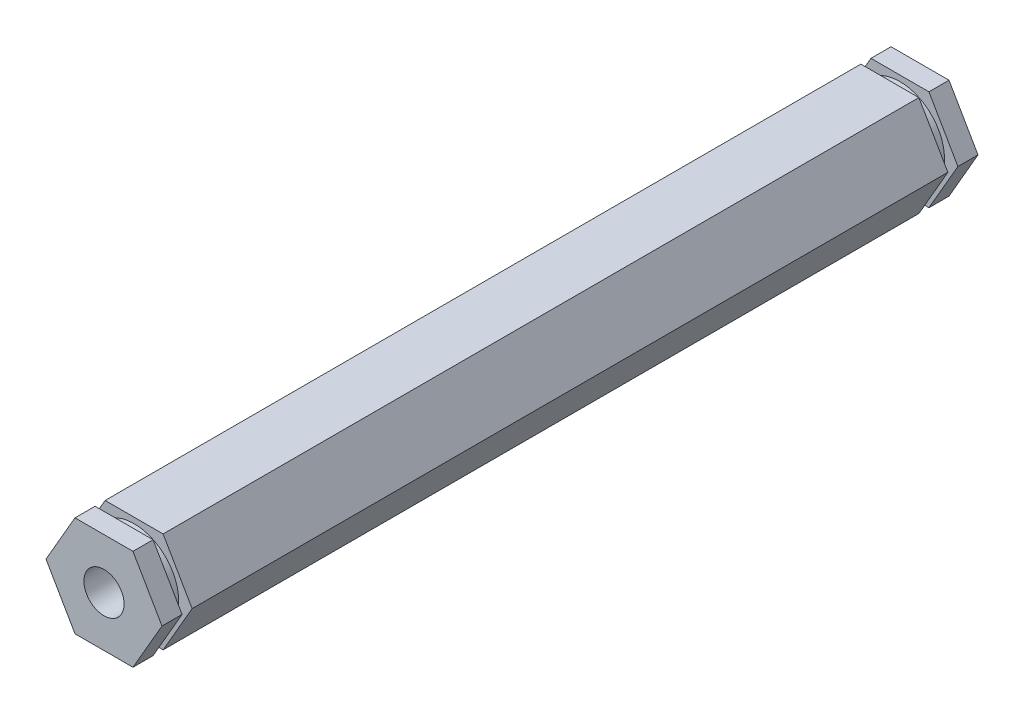
from build123d import *

# Parameters (mm, degrees)
BOSS_EXTRUDE1_DEPTH = 103.1875
SKETCH2_R           = 9.90966703
SKETCH2_R_2         = 5.635297177
CUT_EXTRUDE1_DEPTH  = 1.27
SKETCH3_R           = 2.54
CUT_EXTRUDE2_DEPTH  = 25.4
CUT_EXTRUDE3_START  = -1.27
SKETCH4_R           = 26.134229338
SKETCH4_R_2         = 5.635297177
CUT_EXTRUDE3_DEPTH  = 1.27
CUT_EXTRUDE4_START  = -25.4
SKETCH5_R           = 2.54
CUT_EXTRUDE4_DEPTH  = 25.4


with BuildPart() as part:
    # Sketch1 → Boss-Extrude1 (new body)
    with BuildSketch(Plane.XY):
        Polygon((7.332348419, 0), (3.666174209, 6.35), (-3.666174209, 6.35), (-7.332348419, 0), (-3.666174209, -6.35), (3.666174209, -6.35), align=None)
    extrude(amount=BOSS_EXTRUDE1_DEPTH)

    # Sketch2 → Cut-Extrude1 (cut)
    with BuildSketch(Plane.XY.offset(2.54)):
        Circle(SKETCH2_R)
        Circle(SKETCH2_R_2, mode=Mode.SUBTRACT)
    extrude(amount=CUT_EXTRUDE1_DEPTH, mode=Mode.SUBTRACT)

    # Sketch3 → Cut-Extrude2 (cut)
    with BuildSketch(Plane(origin=(0, 0, 0), x_dir=(-1, 0, 0), z_dir=(0, 0, -1))):
        Circle(SKETCH3_R)
    extrude(amount=-CUT_EXTRUDE2_DEPTH, mode=Mode.SUBTRACT)

    # Sketch4 → Cut-Extrude3 (cut)
    with BuildSketch(Plane.XY.offset(100.6475).offset(CUT_EXTRUDE3_START)):
        Circle(SKETCH4_R)
        Circle(SKETCH4_R_2, mode=Mode.SUBTRACT)
    extrude(amount=CUT_EXTRUDE3_DEPTH, mode=Mode.SUBTRACT)

    # Sketch5 → Cut-Extrude4 (cut)
    with BuildSketch(Plane.XY.offset(103.1875).offset(CUT_EXTRUDE4_START)):
        Circle(SKETCH5_R)
    extrude(amount=CUT_EXTRUDE4_DEPTH, mode=Mode.SUBTRACT)


solid = part.part
